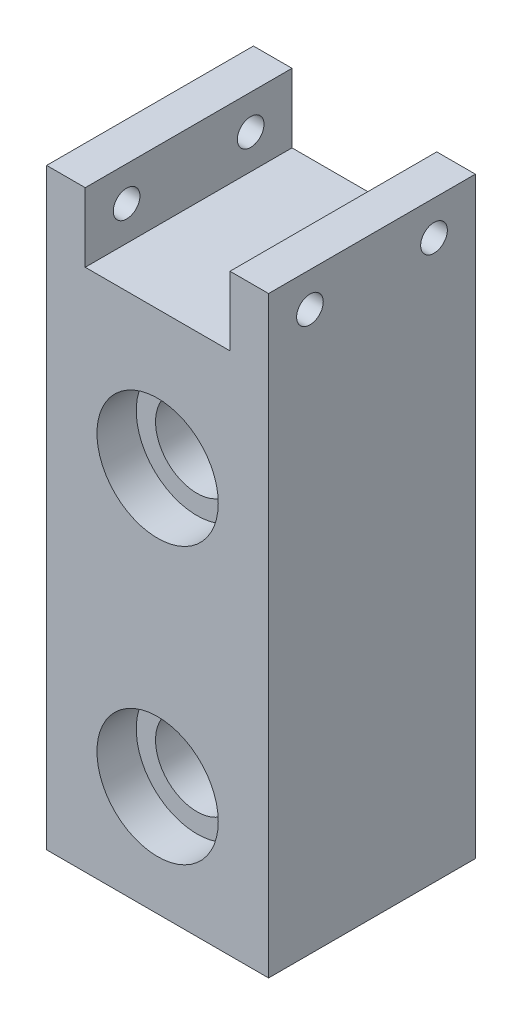
from build123d import *

# Parameters (mm, degrees)
BOSS_EXTRUDE1_DEPTH          = 19.05
SKETCH7_R                    = 7.62
CUT_EXTRUDE2_DEPTH           = 38.1
SKETCH2_R                    = 11.176
CUT_EXTRUDE1_DEPTH           = 7.239
SKETCH8_R                    = 11.176
CUT_EXTRUDE3_DEPTH           = 7.239
F_10_0_1935_DIAMETER_HOLE1_D = 4.9149


with BuildPart() as part:
    # Sketch1 → Boss-Extrude1 (new body, symmetric)
    with BuildSketch(Plane.XY):
        Polygon((13.335, 25.4), (-13.335, 25.4), (-13.335, 38.1), (-20.447, 38.1), (-20.447, -71.12), (20.447, -71.12), (20.447, 38.1), (13.335, 38.1), align=None)
    extrude(amount=BOSS_EXTRUDE1_DEPTH, both=True)

    # Sketch7 → Cut-Extrude2 (cut)
    with BuildSketch(Plane.XY.offset(19.05)):
        Circle(SKETCH7_R)
        with Locations((0, -50.8)):
            Circle(SKETCH7_R)
    extrude(amount=-CUT_EXTRUDE2_DEPTH, mode=Mode.SUBTRACT)

    # Sketch2 → Cut-Extrude1 (cut)
    with BuildSketch(Plane.XY.offset(19.05)):
        Circle(SKETCH2_R)
        with Locations((0, -50.8)):
            Circle(SKETCH2_R)
    extrude(amount=-CUT_EXTRUDE1_DEPTH, mode=Mode.SUBTRACT)

    # Sketch8 → Cut-Extrude3 (cut)
    with BuildSketch(Plane.XY.offset(-19.05)):
        Circle(SKETCH8_R)
        with Locations((0, -50.8)):
            Circle(SKETCH8_R)
    extrude(amount=CUT_EXTRUDE3_DEPTH, mode=Mode.SUBTRACT)

    # #10 (0.1935) Diameter Hole1 (through all)
    with Locations(Plane(origin=(20.447, 0, 0), x_dir=(0, 0, -1), z_dir=(1, 0, 0))):
        with Locations((-11.43, 31.75)):
            f_10_0_1935_diameter_hole1 = Hole(F_10_0_1935_DIAMETER_HOLE1_D / 2)

    # Mirror1: #10 (0.1935) Diameter Hole1 across plane
    add(f_10_0_1935_diameter_hole1.mirror(Plane.XY), mode=Mode.SUBTRACT)


solid = part.part
